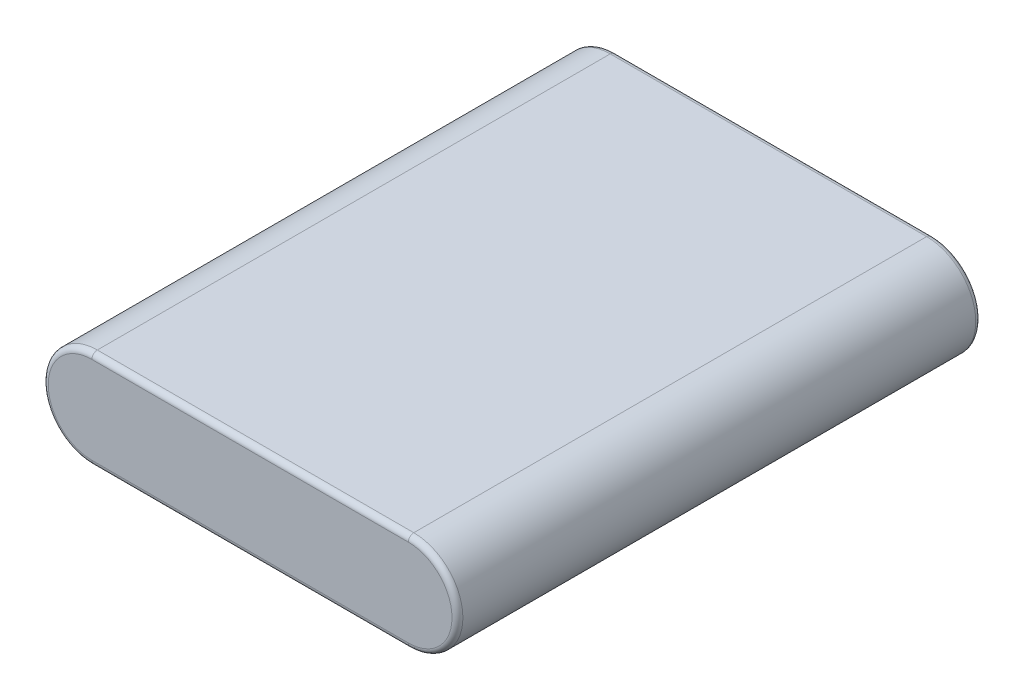
from build123d import *

# Parameters (mm, degrees)
BOSS_EXTRU_1_DEPTH = 96
CONG_1_R           = 1


with BuildPart() as part:
    # Esquisse1 → Boss.-Extru.1 (new body)
    with BuildSketch(Plane.XY):
        with BuildLine():
            Line((0, 9), (58, 9))
            ThreePointArc((58, 9), (67, 0), (58, -9))
            Line((58, -9), (0, -9))
            ThreePointArc((0, -9), (-9, 0), (0, 9))
        make_face()
    extrude(amount=BOSS_EXTRU_1_DEPTH)

    # Congé1
    cong_1_edges = [part.edges().sort_by_distance(p)[0] for p in [
        (67, 0, 96),
        (29, 9, 96),
        (-9, 0, 96),
        (29, 9, 0),
        (67, 0, 0),
        (29, -9, 0),
        (-9, 0, 0),
        (29, -9, 96),
    ]]
    fillet(cong_1_edges, radius=CONG_1_R)


solid = part.part
